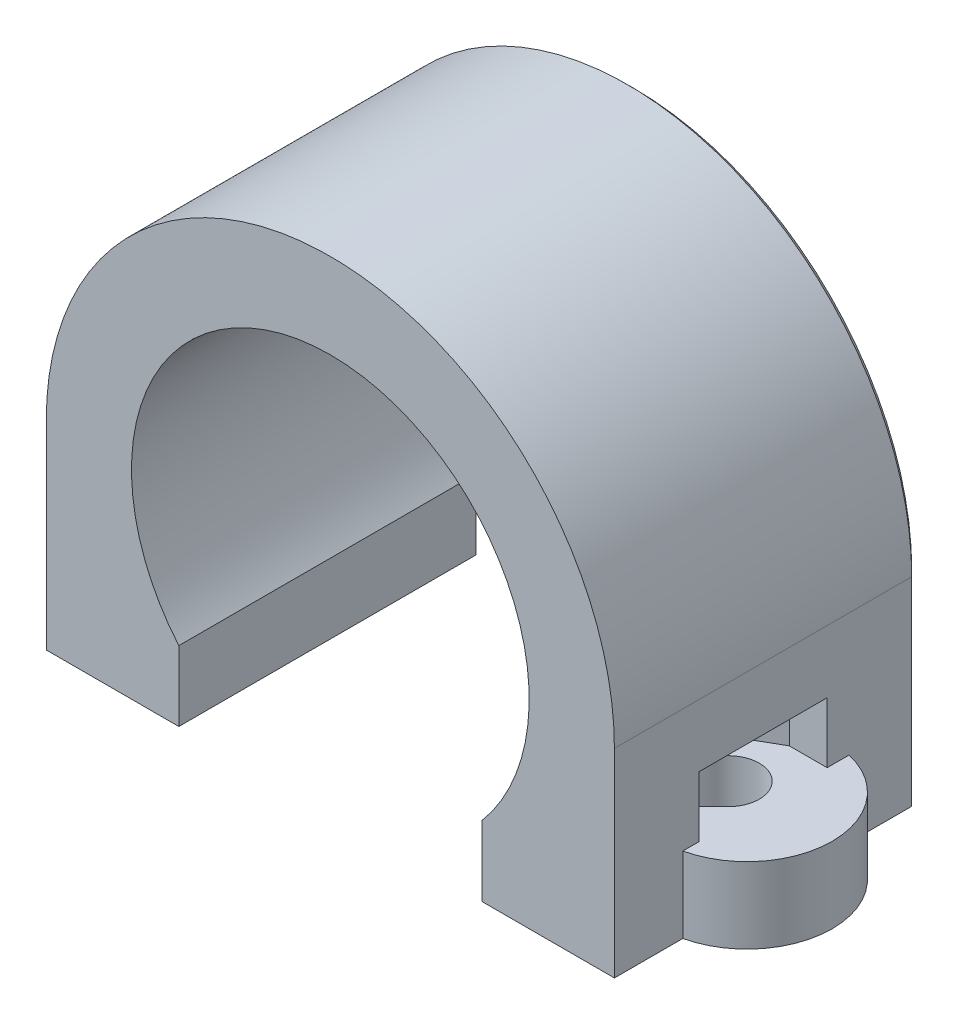
from build123d import *

# Parameters (mm, degrees)
BOSS_EXTRUDE1_DEPTH = 16
SKETCH4_R           = 4.5
BOSS_EXTRUDE2_DEPTH = 4
SKETCH2_R           = 1.65
CUT_EXTRUDE1_DEPTH  = 10
CUT_EXTRUDE2_START  = -4
CUT_EXTRUDE2_DEPTH  = 3.2
CHAMFER1_SIZE       = 0.3
CUT_EXTRUDE3_DEPTH  = 10


with BuildPart() as part:
    # Sketch1 → Boss-Extrude1 (new body)
    with BuildSketch(Plane.XY):
        with BuildLine():
            Line((8, -6.800735254), (8, -10.5))
            Line((8, -10.5), (15, -10.5))
            Line((15, -10.5), (15, 0))
            ThreePointArc((15, 0), (0, 15), (-15, 0))
            Line((-15, 0), (-15, -10.5))
            Line((-15, -10.5), (-8, -10.5))
            Line((-8, -10.5), (-8, -6.800735254))
            ThreePointArc((-8, -6.800735254), (0, 10.5), (8, -6.800735254))
        make_face()
    extrude(amount=BOSS_EXTRUDE1_DEPTH)

    # Sketch4 → Boss-Extrude2 (add)
    with BuildSketch(Plane.XZ.offset(10.5)):
        with Locations((14, 8)):
            Circle(SKETCH4_R)
    boss_extrude2 = extrude(amount=-BOSS_EXTRUDE2_DEPTH)

    # Sketch2 → Cut-Extrude1 (cut)
    with BuildSketch(Plane.XZ.offset(10.5)):
        with Locations((13, 8)):
            Circle(SKETCH2_R)
    cut_extrude1 = extrude(amount=-CUT_EXTRUDE1_DEPTH, mode=Mode.SUBTRACT)

    # Sketch3 → Cut-Extrude2 (cut)
    with BuildSketch(Plane.XZ.offset(10.5).offset(CUT_EXTRUDE2_START)):
        Polygon((10.2, 9.616580754), (10.2, 9.916580754), (13, 11.533161507), (17.758039714, 11.533161507), (17.758039714, 11.233161507), (17.758039714, 4.766838493), (13, 4.766838493), (10.2, 6.383419246), align=None)
    cut_extrude2 = extrude(amount=-CUT_EXTRUDE2_DEPTH, mode=Mode.SUBTRACT)

    # Mirror1: Boss-Extrude2, Cut-Extrude1, Cut-Extrude2 across plane
    add(boss_extrude2.mirror(Plane(origin=(0, 0, 0), x_dir=(0, 0, 1), z_dir=(1, 0, 0))))
    add(cut_extrude1.mirror(Plane(origin=(0, 0, 0), x_dir=(0, 0, 1), z_dir=(1, 0, 0))), mode=Mode.SUBTRACT)
    add(cut_extrude2.mirror(Plane(origin=(0, 0, 0), x_dir=(0, 0, 1), z_dir=(1, 0, 0))), mode=Mode.SUBTRACT)

    # Chamfer1
    chamfer1_edges = [part.edges().sort_by_distance(p)[0] for p in [
        (-15, -5.25, 0),
        (0, 15, 0),
        (15, -5.25, 0),
        (11.5, -10.5, 0),
        (8, -8.650367627, 0),
        (0, 10.5, 0),
        (-8, -8.650367627, 0),
        (-11.5, -10.5, 0),
    ]]
    chamfer(chamfer1_edges, length=CHAMFER1_SIZE)

    # Sketch5 → Cut-Extrude3 (cut)
    with BuildSketch(Plane.XZ.offset(10.5)):
        Polygon((-13, 8), (-11.833273811, 9.166726189), (-12.636547622, 9.97), (-13.363452378, 9.97), (-14.166726189, 9.166726189), align=None)
        Polygon((13, 8), (14.166726189, 9.166726189), (13.363452378, 9.97), (12.636547622, 9.97), (11.833273811, 9.166726189), align=None)
    extrude(amount=-CUT_EXTRUDE3_DEPTH, mode=Mode.SUBTRACT)


solid = part.part
